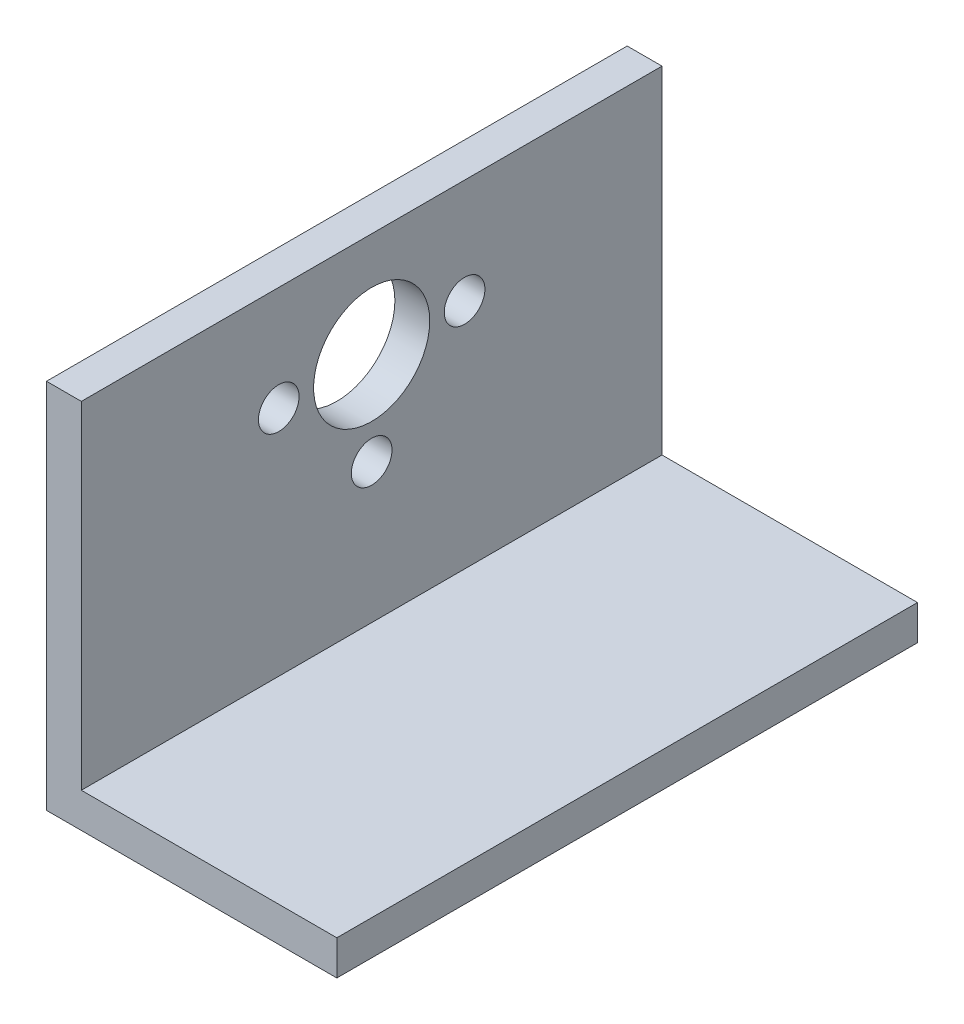
from build123d import *

# Parameters (mm, degrees)
BOSS_EXTRUDE1_DEPTH            = 50
HOLE_FOR_M5_300_SC_NUTS_SP_1_D = 10
HOLE_FOR_M5_300_SC_NUTS_SP_2_D = 3.5


with BuildPart() as part:
    # Sketch1 → Boss-Extrude1 (new body)
    with BuildSketch(Plane.XY):
        Polygon((-7.897485035, 31.347562808), (-7.897485035, 2.347562808), (14.102514965, 2.347562808), (14.102514965, -0.652437192), (-10.897485035, -0.652437192), (-10.897485035, 31.347562808), align=None)
    extrude(amount=BOSS_EXTRUDE1_DEPTH)

    # Hole for M5 300® SC Nuts (SP)1 (through all)
    with Locations(Plane(origin=(-7.897485035, 0, 0), x_dir=(0, 0, -1), z_dir=(1, 0, 0))):
        with Locations((-25, 22.347562808)):
            Hole(HOLE_FOR_M5_300_SC_NUTS_SP_1_D / 2)

    # Hole for M5 300® SC Nuts (SP)2 (through all)
    with Locations(Plane(origin=(-7.897485035, 0, 0), x_dir=(0, 0, -1), z_dir=(1, 0, 0))):
        with Locations((-17, 22.347562808), (-33, 22.347562808), (-25, 14.347562808)):
            Hole(HOLE_FOR_M5_300_SC_NUTS_SP_2_D / 2)


solid = part.part
